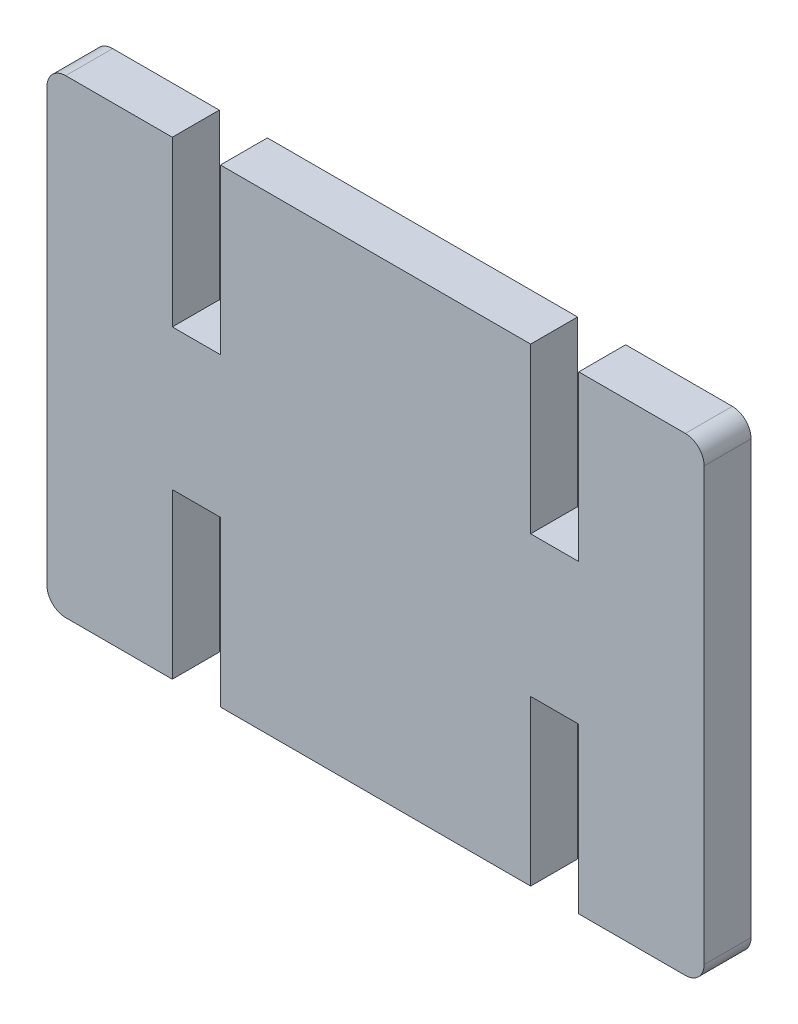
from build123d import *

# Parameters (mm, degrees)
BOSS_EXTRUDE1_DEPTH = 5
SKETCH2_W           = 5.125
SKETCH2_H           = 17.5
CUT_EXTRUDE1_DEPTH  = 5


with BuildPart() as part:
    # Sketch1 → Boss-Extrude1 (new body)
    with BuildSketch(Plane.XY):
        with BuildLine():
            Line((2, 0), (68, 0))
            ThreePointArc((68, 0), (69.414213562, 0.585786438), (70, 2))
            Line((70, 2), (70, 48))
            ThreePointArc((70, 48), (69.414213562, 49.414213562), (68, 50))
            Line((68, 50), (2, 50))
            ThreePointArc((2, 50), (0.585786438, 49.414213562), (0, 48))
            Line((0, 48), (0, 2))
            ThreePointArc((0, 2), (0.585786438, 0.585786438), (2, 0))
        make_face()
    extrude(amount=BOSS_EXTRUDE1_DEPTH)

    # Sketch2 → Cut-Extrude1 (cut)
    with BuildSketch(Plane(origin=(-23.39926368, 94.916866164, 5), x_dir=(1, 0, 0), z_dir=(0, 0, 1))):
        with Locations((39.316333928, -53.666866164)):
            Rectangle(SKETCH2_W, SKETCH2_H)
        with Locations((77.482193432, -53.666866164)):
            Rectangle(SKETCH2_W, SKETCH2_H)
        with Locations((39.316333928, -86.166866164)):
            Rectangle(SKETCH2_W, SKETCH2_H)
        with Locations((77.482193432, -86.166866164)):
            Rectangle(SKETCH2_W, SKETCH2_H)
    extrude(amount=-CUT_EXTRUDE1_DEPTH, mode=Mode.SUBTRACT)


solid = part.part
